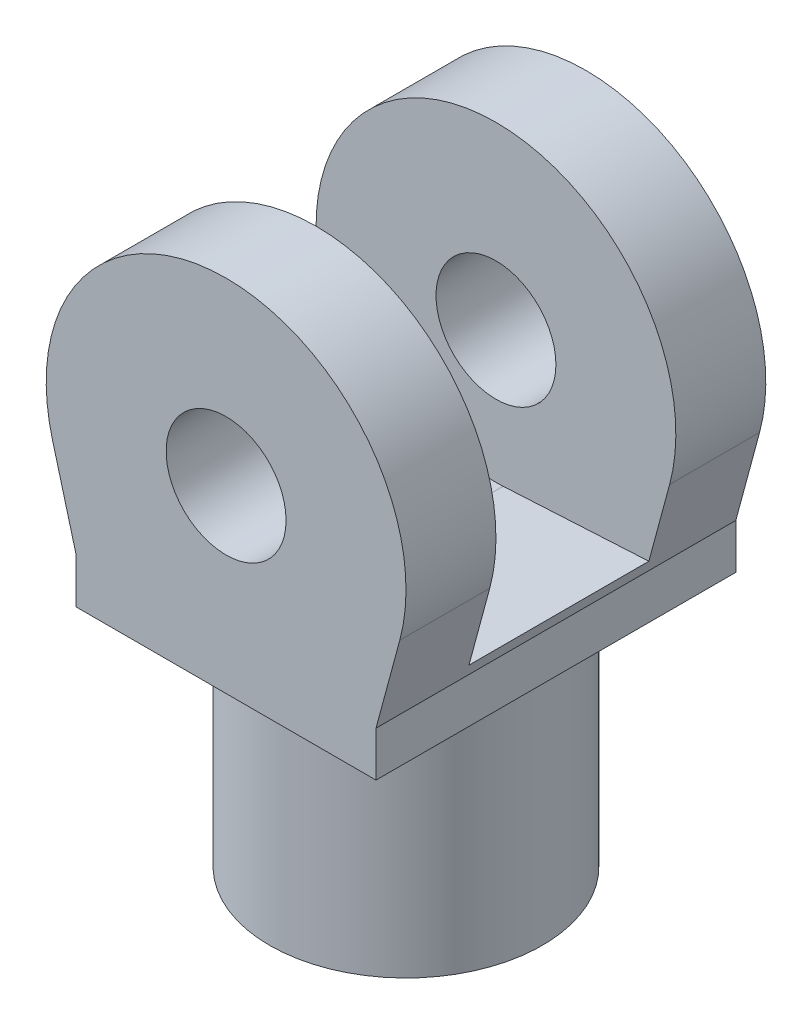
from build123d import *

# Parameters (mm, degrees)
SKETCH8_R           = 2.275
BOSS_EXTRUDE4_DEPTH = 4
SKETCH9_W           = 5
SKETCH9_H           = 6
BOSS_EXTRUDE5_DEPTH = 0.75
SKETCH10_R          = 1
BOSS_EXTRUDE6_DEPTH = 3
CUT_EXTRUDE2_DEPTH  = 1.5


with BuildPart() as part:
    # Sketch8 → Boss-Extrude4 (new body)
    with BuildSketch(Plane(origin=(0, 0, 0), x_dir=(1, 0, 0), z_dir=(0, 1, 0))):
        Circle(SKETCH8_R)
    extrude(amount=BOSS_EXTRUDE4_DEPTH)

    # Sketch9 → Boss-Extrude5 (add)
    with BuildSketch(Plane(origin=(0, 4, 0), x_dir=(1, 0, 0), z_dir=(0, 1, 0))):
        Rectangle(SKETCH9_W, SKETCH9_H)
    extrude(amount=BOSS_EXTRUDE5_DEPTH)

    # Sketch10 → Boss-Extrude6 (add, symmetric)
    with BuildSketch(Plane.XY):
        with BuildLine():
            Line((-2.896323692, 6.218137436), (-2.5, 4.75))
            Line((-2.5, 4.75), (2.5, 4.75))
            Line((2.5, 4.75), (2.896323692, 6.218137436))
            ThreePointArc((2.896323692, 6.218137436), (0, 10), (-2.896323692, 6.218137436))
        make_face()
        with Locations((0, 7)):
            Circle(SKETCH10_R, mode=Mode.SUBTRACT)
    extrude(amount=BOSS_EXTRUDE6_DEPTH, both=True)

    # Sketch11 → Cut-Extrude2 (cut, symmetric)
    with BuildSketch(Plane.XY):
        with BuildLine():
            Line((-0.119661192, 4.803256683), (-17.5, 5.75))
            Line((-17.5, 5.75), (-17.5, 11.234268724))
            Line((-17.5, 11.234268724), (17.5, 11.234268724))
            Line((17.5, 11.234268724), (17.5, 5.75))
            Line((17.5, 5.75), (0.119661192, 4.803256683))
            ThreePointArc((0.119661192, 4.803256683), (0, 4.8), (-0.119661192, 4.803256683))
        make_face()
    extrude(amount=CUT_EXTRUDE2_DEPTH, both=True, mode=Mode.SUBTRACT)


solid = part.part
